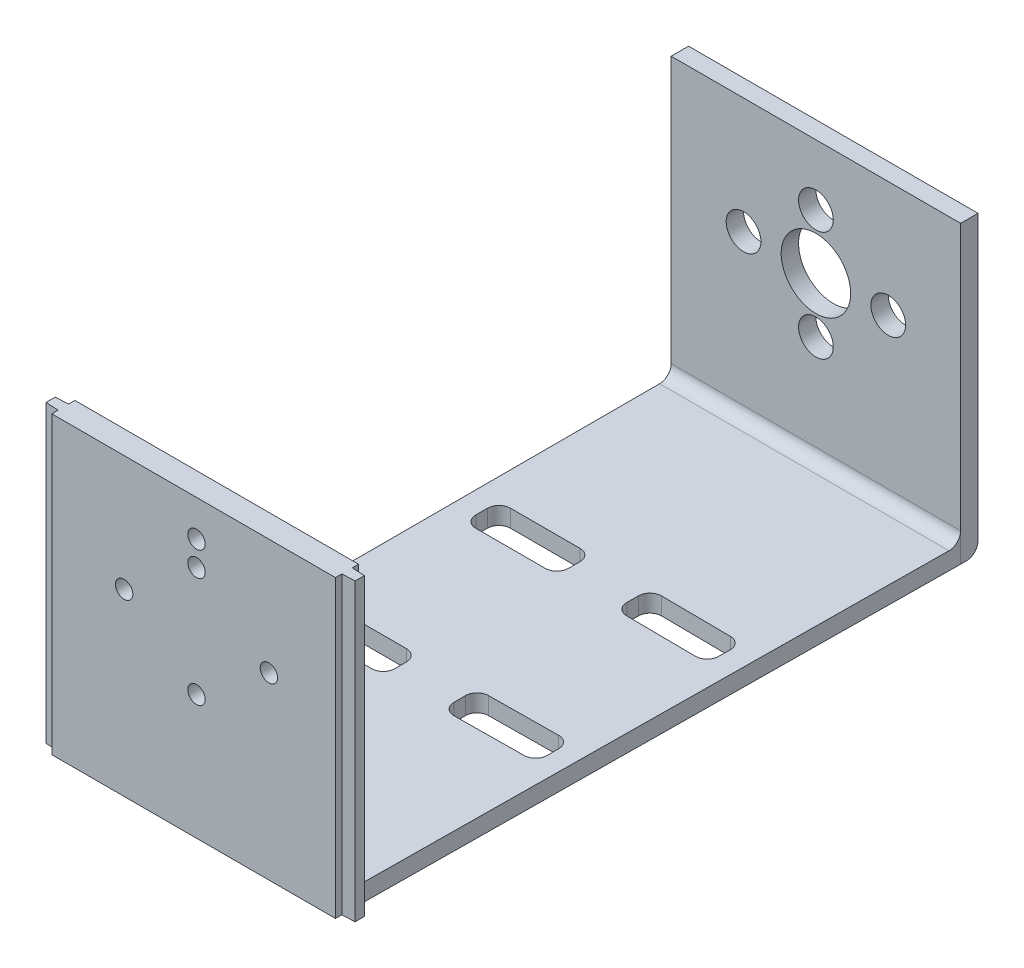
from build123d import *

# Parameters (mm, degrees)
SKETCH_1_W      = 50
SKETCH_1_H      = 51
SKETCH_1_R      = 6
SKETCH_1_R_2    = 3
EXTRUDE_1_DEPTH = 3
SKETCH_2_W      = 16
SKETCH_2_H      = 6
EXTRUDE_2_DEPTH = 3
SKETCH_3_W      = 49
SKETCH_3_H      = 51
SKETCH_3_R      = 1.5
EXTRUDE_3_DEPTH = 4
FILLET_2_R      = 2
FILLET_3_R      = 2
FILLET_4_R      = 2
FILLET_5_R      = 2
FILLET_6_R      = 2
EXTRUDE_5_DEPTH = 51


with BuildPart() as part:
    # 草图1 → 凸台-拉伸1 (new body)
    with BuildSketch(Plane.XY):
        with Locations((0, -5.5)):
            Rectangle(SKETCH_1_W, SKETCH_1_H)
        Circle(SKETCH_1_R, mode=Mode.SUBTRACT)
        with Locations((12.5, 0)):
            Circle(SKETCH_1_R_2, mode=Mode.SUBTRACT)
        with Locations((-12.5, 0)):
            Circle(SKETCH_1_R_2, mode=Mode.SUBTRACT)
        with Locations((0, 9.5)):
            Circle(SKETCH_1_R_2, mode=Mode.SUBTRACT)
        with Locations((0, -9.5)):
            Circle(SKETCH_1_R_2, mode=Mode.SUBTRACT)
    extrude(amount=EXTRUDE_1_DEPTH)

    # 草图2 → 凸台-拉伸2 (add)
    with BuildSketch(Plane.XZ.offset(31)):
        Polygon((-25, 3), (-25, 106), (24, 106), (25, 3), align=None)
        with Locations((-13.25, 39.5)):
            Rectangle(SKETCH_2_W, SKETCH_2_H, mode=Mode.SUBTRACT)
        Polygon((4.866266466, 42.54910809), (4.92451752, 36.549390862), (20.923763461, 36.704727007), (20.865512407, 42.704444235), align=None, mode=Mode.SUBTRACT)
        with Locations((-13.25, 69.5)):
            Rectangle(SKETCH_2_W, SKETCH_2_H, mode=Mode.SUBTRACT)
        Polygon((20.865512407, 66.295555765), (20.923763461, 72.295272993), (4.92451752, 72.450609138), (4.866266466, 66.45089191), align=None, mode=Mode.SUBTRACT)
    extrude(amount=-EXTRUDE_2_DEPTH)

    # 草图3 → 凸台-拉伸3 (add)
    with BuildSketch(Plane.XY.offset(106)):
        with Locations((-0.5, -5.5)):
            Rectangle(SKETCH_3_W, SKETCH_3_H)
        with Locations((-12.5, 0)):
            Circle(SKETCH_3_R, mode=Mode.SUBTRACT)
        with Locations((12.5, 0)):
            Circle(SKETCH_3_R, mode=Mode.SUBTRACT)
        with Locations((0, -9.5)):
            Circle(SKETCH_3_R, mode=Mode.SUBTRACT)
        with Locations((0, 9.5)):
            Circle(SKETCH_3_R, mode=Mode.SUBTRACT)
        with Locations((0, 13.75)):
            Circle(SKETCH_3_R, mode=Mode.SUBTRACT)
    extrude(amount=EXTRUDE_3_DEPTH)

    # 圆角2
    fillet_2_edges = [part.edges().sort_by_distance(p)[0] for p in [
        (-5.25, -29.5, 36.5),
    ]]
    fillet(fillet_2_edges, radius=FILLET_2_R)

    # 圆角3
    fillet_3_edges = [part.edges().sort_by_distance(p)[0] for p in [
        (-21.25, -29.5, 36.5),
        (-21.25, -29.5, 42.5),
        (-5.25, -29.5, 42.5),
    ]]
    fillet(fillet_3_edges, radius=FILLET_3_R)

    # 圆角4
    fillet_4_edges = [part.edges().sort_by_distance(p)[0] for p in [
        (20.865512407, -29.5, 42.704444235),
        (20.923763461, -29.5, 36.704727007),
        (4.92451752, -29.5, 36.549390862),
        (4.866266466, -29.5, 42.54910809),
        (-21.25, -29.5, 66.5),
        (-21.25, -29.5, 72.5),
        (-5.25, -29.5, 72.5),
        (-5.25, -29.5, 66.5),
        (4.866266466, -29.5, 66.45089191),
        (4.92451752, -29.5, 72.450609138),
        (20.923763461, -29.5, 72.295272993),
        (20.865512407, -29.5, 66.295555765),
    ]]
    fillet(fillet_4_edges, radius=FILLET_4_R)

    # 圆角5
    fillet_5_edges = [part.edges().sort_by_distance(p)[0] for p in [
        (0, -28, 3),
    ]]
    fillet(fillet_5_edges, radius=FILLET_5_R)

    # 圆角6
    fillet_6_edges = [part.edges().sort_by_distance(p)[0] for p in [
        (0, -31, 0),
    ]]
    fillet(fillet_6_edges, radius=FILLET_6_R)

    # 草图6 → 凸台-拉伸5 (add)
    with BuildSketch(Plane(origin=(0, -31, 0), x_dir=(-1, 0, 0), z_dir=(0, -1, 0))):
        Polygon((-24, -108.9), (-23.989320388, -107.1), (-26.2, -107.2), (-26.2, -108.8), align=None)
        Polygon((25, -108.9), (24.989320388, -107.1), (27.2, -107.2), (27.2, -108.8), align=None)
    extrude(amount=-EXTRUDE_5_DEPTH)


solid = part.part
